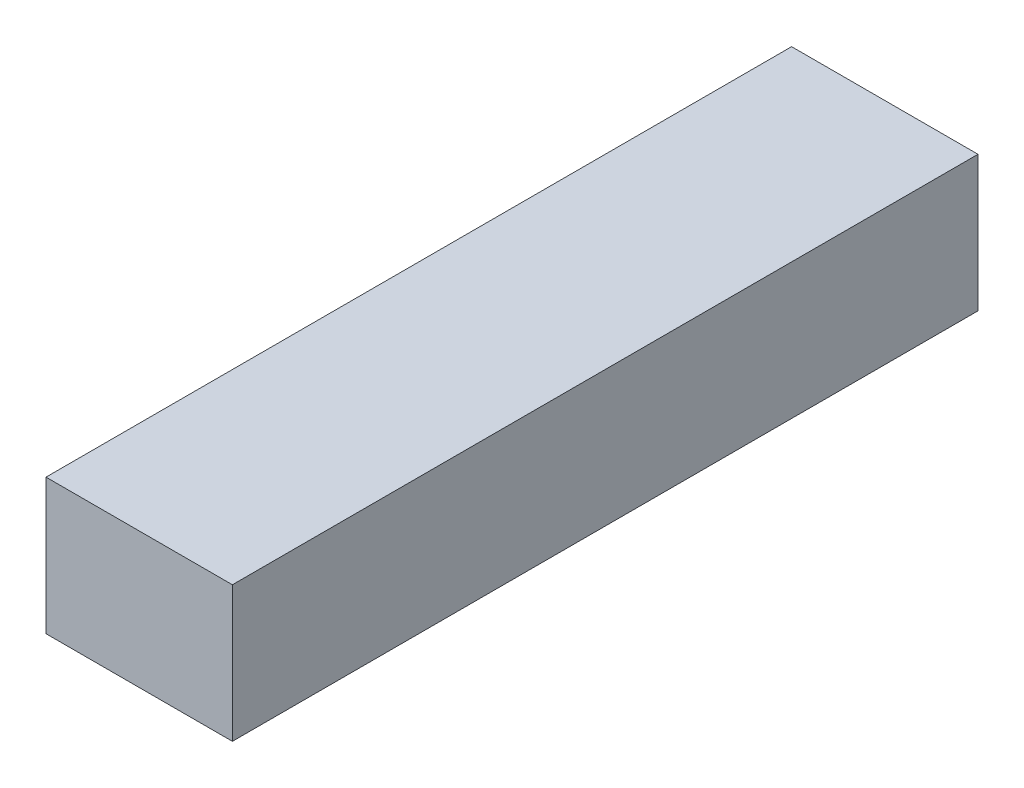
from build123d import *

# Parameters (mm, degrees)
SKETCH1_W           = 6.35
SKETCH1_H           = 4.62
BOSS_EXTRUDE1_DEPTH = 25.4


with BuildPart() as part:
    # Sketch1 → Boss-Extrude1 (new body)
    with BuildSketch(Plane.XY):
        Rectangle(SKETCH1_W, SKETCH1_H)
    extrude(amount=BOSS_EXTRUDE1_DEPTH)


solid = part.part
